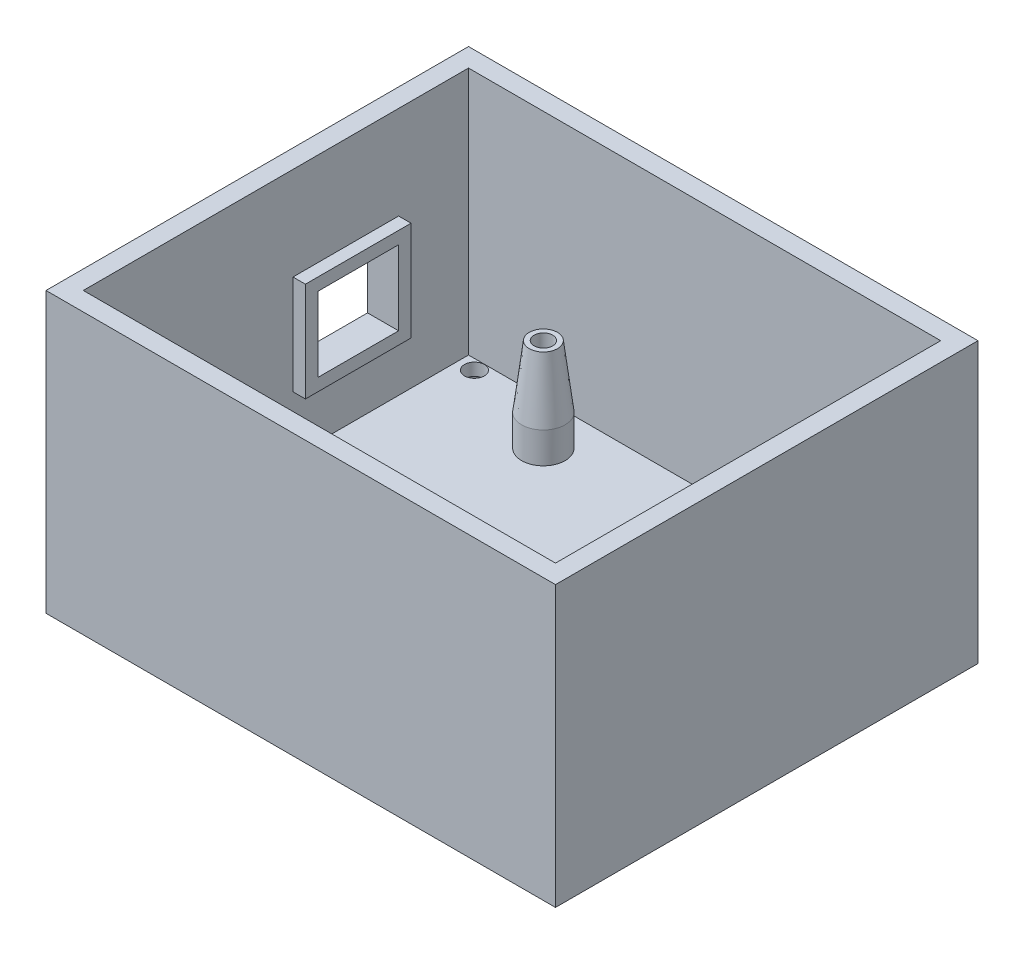
from build123d import *

# Parameters (mm, degrees)
SKETCH1_W           = 82
SKETCH1_H           = 68
BOSS_EXTRUDE1_DEPTH = 5
SKETCH2_W           = 82
SKETCH2_H           = 68
SKETCH2_W_2         = 76
SKETCH2_H_2         = 62
BOSS_EXTRUDE2_DEPTH = 40
SKETCH_1_R          = 3.5
SKETCH_1_R_2        = 1.5
BOSS_EXTRUDE3_DEPTH = 15
SKETCH4_W           = 13
SKETCH4_H           = 12
CUT_EXTRUDE1_DEPTH  = 3
SKETCH5_R           = 1.6
CUT_EXTRUDE2_DEPTH  = 46
SKETCH6_W           = 1.038961039
SKETCH6_H           = 16
SKETCH6_W_2         = 1.038961038
SKETCH6_W_3         = 0.935064935
SKETCH6_H_2         = 6
BOSS_EXTRUDE4_DEPTH = 1
SKETCH7_R           = 1.6
CUT_EXTRUDE3_DEPTH  = 46.0000001
CUT_EXTRUDE4_DEPTH  = 3
SKETCH10_W          = 17
SKETCH10_H          = 16
SKETCH10_W_2        = 13
SKETCH10_H_2        = 12
BOSS_EXTRUDE6_DEPTH = 2
CHAMFER1_SIZE       = 10
CHAMFER1_SIZE2      = 1.227845609
CUT_EXTRUDE5_DEPTH  = 3


with BuildPart() as part:
    # Sketch1 → Boss-Extrude1 (new body)
    with BuildSketch(Plane(origin=(0, 0, 0), x_dir=(1, 0, 0), z_dir=(0, 1, 0))):
        Rectangle(SKETCH1_W, SKETCH1_H)
    extrude(amount=BOSS_EXTRUDE1_DEPTH)

    # Sketch2 → Boss-Extrude2 (add)
    with BuildSketch(Plane(origin=(0, 5, 0), x_dir=(1, 0, 0), z_dir=(0, 1, 0))):
        Rectangle(SKETCH2_W, SKETCH2_H)
        Rectangle(SKETCH2_W_2, SKETCH2_H_2, mode=Mode.SUBTRACT)
    extrude(amount=BOSS_EXTRUDE2_DEPTH)

    # Эскиз1 → Boss-Extrude3 (add)
    with BuildSketch(Plane(origin=(0, 5, 0), x_dir=(1, 0, 0), z_dir=(0, 1, 0))):
        with Locations(Location((-20.3, -24.15, 0), (0, 0, 90))):  # turned: the seam where the file's is
            Circle(SKETCH_1_R)
        with Locations(Location((-20.3, -24.15, 0), (0, 0, 270))):  # turned: the seam where the file's is
            Circle(SKETCH_1_R_2, mode=Mode.SUBTRACT)
        with Locations(Location((-19, 24.05, 0), (0, 0, 90))):  # turned: the seam where the file's is
            Circle(SKETCH_1_R)
        with Locations(Location((-19, 24.05, 0), (0, 0, 270))):  # turned: the seam where the file's is
            Circle(SKETCH_1_R_2, mode=Mode.SUBTRACT)
        with Locations(Location((31.8, 8.85, 0), (0, 0, 90))):  # turned: the seam where the file's is
            Circle(SKETCH_1_R)
        with Locations(Location((31.8, 8.85, 0), (0, 0, 270))):  # turned: the seam where the file's is
            Circle(SKETCH_1_R_2, mode=Mode.SUBTRACT)
        with Locations(Location((31.8, -19.05, 0), (0, 0, 90))):  # turned: the seam where the file's is
            Circle(SKETCH_1_R)
        with Locations(Location((31.8, -19.05, 0), (0, 0, 270))):  # turned: the seam where the file's is
            Circle(SKETCH_1_R_2, mode=Mode.SUBTRACT)
    extrude(amount=BOSS_EXTRUDE3_DEPTH)

    # Sketch4 → Cut-Extrude1 (cut)
    with BuildSketch(Plane.ZY.offset(41)):
        with Locations((-11.25, 22)):
            Rectangle(SKETCH4_W, SKETCH4_H)
    extrude(amount=-CUT_EXTRUDE1_DEPTH, mode=Mode.SUBTRACT)

    # Sketch5 → Cut-Extrude2 (cut, through all)
    with BuildSketch(Plane.XZ):
        with Locations(Location((-20, 0, 0), (0, 0, 270))):  # turned: the seam where the file's is
            Circle(SKETCH5_R)
        with Locations(Location((20, 0, 0), (0, 0, 270))):  # turned: the seam where the file's is
            Circle(SKETCH5_R)
    extrude(amount=-CUT_EXTRUDE2_DEPTH, mode=Mode.SUBTRACT)

    # Sketch6 → Boss-Extrude4 (add)
    with BuildSketch(Plane(origin=(0, 0, -34), x_dir=(-1, 0, 0), z_dir=(0, 0, -1))):
        with BuildLine():
            Line((-31.064935065, 20.402597403), (-30.025974026, 20.61038961))
            add(Edge.make_bspline(
                [(-30.025974026, 20.61038961), (-30.016868414, 20.484792918), (-29.999188975, 20.240934613), (-29.963126926, 19.888060515), (-29.922684502, 19.558454016), (-29.868885391, 19.254851974), (-29.815998127, 18.973437018), (-29.750829493, 18.717933849), (-29.679471521, 18.485959946), (-29.602554708, 18.278361569), (-29.518303648, 18.094044446), (-29.424992346, 17.9348933), (-29.323309249, 17.800144607), (-29.217010337, 17.687767881), (-29.101116364, 17.602086662), (-28.980181431, 17.538341624), (-28.849524042, 17.501328913), (-28.759967332, 17.496148797), (-28.714285714, 17.493506494)],
                knots=[0, 0, 0, 0, 1.661687727, 3.226329817, 4.680708754, 6.04252312, 7.294539854, 8.458411098, 9.519995036, 10.49619686, 11.377985793, 12.191180799, 12.925279752, 13.601980054, 14.224680614, 14.818714541, 15.397442913, 16, 16, 16, 16], degree=3))
            add(Edge.make_bspline(
                [(-28.714285714, 17.493506494), (-28.626175383, 17.500509622), (-28.449894153, 17.514520693), (-28.207810204, 17.6461628), (-27.999947032, 17.851229771), (-27.833671953, 18.130415132), (-27.701639144, 18.463631904), (-27.600422532, 18.838132976), (-27.542705985, 19.251458609), (-27.53597212, 19.538778349), (-27.532467532, 19.688311688)],
                knots=[0, 0, 0, 0, 0.766738448, 1.534003965, 2.351769453, 3.301198784, 4.355496104, 5.484396366, 6.690773518, 8, 8, 8, 8], degree=3))
            add(Edge.make_bspline(
                [(-27.532467532, 19.688311688), (-27.533389047, 19.776023561), (-27.535167264, 19.945278246), (-27.557846971, 20.189547654), (-27.596587743, 20.413063993), (-27.663390633, 20.677065304), (-27.783838204, 20.969797211), (-27.97376884, 21.225964657), (-28.187671526, 21.415109589), (-28.416744466, 21.594638473), (-28.711370171, 21.820842523), (-28.9374622, 21.976282127), (-29.061688312, 22.061688312)],
                knots=[0, 0, 0, 0, 0.876287264, 1.6909424, 2.448383105, 3.140885154, 4.410446652, 5.584964704, 6.289190717, 7.258693585, 8.493791056, 10, 10, 10, 10], degree=3))
            add(Edge.make_bspline(
                [(-29.061688312, 22.061688312), (-29.176027715, 22.144958584), (-29.396314269, 22.305387279), (-29.687605647, 22.574624434), (-29.933601391, 22.852159883), (-30.132337823, 23.152195988), (-30.291814378, 23.482805462), (-30.434092879, 23.851134876), (-30.560507571, 24.264385407), (-30.664991897, 24.720419442), (-30.752188862, 25.207848635), (-30.813484827, 25.719495048), (-30.849036698, 26.248407051), (-30.854415503, 26.607089174), (-30.857142857, 26.788961039)],
                knots=[0, 0, 0, 0, 0.963949184, 1.857146694, 2.699365597, 3.487487385, 4.302789044, 5.197814381, 6.178376633, 7.247190379, 8.386632243, 9.553870898, 10.759675959, 12, 12, 12, 12], degree=3))
            add(Edge.make_bspline(
                [(-30.857142857, 26.788961039), (-30.854088378, 26.999000885), (-30.848128221, 27.408848298), (-30.799885602, 28.008787466), (-30.714577868, 28.575439797), (-30.604547612, 29.107114264), (-30.460010213, 29.58896524), (-30.294001435, 30.015155377), (-30.098806507, 30.377162712), (-29.878519584, 30.677513141), (-29.628480853, 30.915703506), (-29.346923858, 31.084038645), (-29.037809403, 31.191192244), (-28.821215613, 31.202195225), (-28.711038961, 31.207792208)],
                knots=[0, 0, 0, 0, 1.401640024, 2.734997902, 4.012817877, 5.223990224, 6.355074786, 7.366334982, 8.271317923, 9.091800892, 9.842980832, 10.558924655, 11.266955634, 12, 12, 12, 12], degree=3))
            add(Edge.make_bspline(
                [(-28.711038961, 31.207792208), (-28.627370875, 31.204138543), (-28.462252224, 31.196928051), (-28.222436212, 31.136840846), (-27.99884274, 31.03686606), (-27.786960968, 30.902088863), (-27.591899336, 30.724420824), (-27.414006672, 30.506989796), (-27.24644712, 30.254107306), (-27.096667117, 29.962567439), (-26.959967183, 29.63583311), (-26.840317666, 29.27559408), (-26.741198491, 28.881243436), (-26.657070805, 28.455305488), (-26.589518587, 27.995855065), (-26.537514645, 27.503096433), (-26.505933925, 26.976566886), (-26.497728837, 26.614758323), (-26.493506494, 26.428571429)],
                knots=[0, 0, 0, 0, 0.695412281, 1.372393508, 2.041605889, 2.725971717, 3.452793057, 4.226354358, 5.057948934, 5.972157744, 6.948753067, 8.002263538, 9.126939128, 10.329474995, 11.613047353, 12.989221996, 14.450651905, 16, 16, 16, 16], degree=3))
            Line((-26.493506494, 26.428571429), (-27.532467532, 26.220779221))
            add(Edge.make_bspline(
                [(-27.532467532, 26.220779221), (-27.54093835, 26.322517805), (-27.557262626, 26.518580213), (-27.583864063, 26.80176955), (-27.624974622, 27.059954024), (-27.664323563, 27.296009856), (-27.717617625, 27.505485276), (-27.771595461, 27.692649748), (-27.833098451, 27.855684632), (-27.919708269, 28.036784602), (-28.051627643, 28.219924842), (-28.241242291, 28.390288951), (-28.471179714, 28.487943746), (-28.634428531, 28.500235983), (-28.717532468, 28.506493506)],
                knots=[0, 0, 0, 0, 1.296485935, 2.498483323, 3.610200847, 4.615676197, 5.535617839, 6.35305, 7.08812514, 7.745768663, 8.89761878, 9.930610951, 10.946550552, 12, 12, 12, 12], degree=3))
            add(Edge.make_bspline(
                [(-28.717532468, 28.506493506), (-28.801659454, 28.501207248), (-28.963775423, 28.491020421), (-29.191742714, 28.402069528), (-29.384731707, 28.252979321), (-29.54317232, 28.052133814), (-29.663284564, 27.809548914), (-29.755709635, 27.539175905), (-29.80631869, 27.238860673), (-29.814122301, 27.030479772), (-29.818181818, 26.922077922)],
                knots=[0, 0, 0, 0, 0.934315741, 1.800462716, 2.677856118, 3.620837444, 4.623395376, 5.679091747, 6.792640076, 8, 8, 8, 8], degree=3))
            add(Edge.make_bspline(
                [(-29.818181818, 26.922077922), (-29.815762732, 26.815903924), (-29.811079789, 26.610369008), (-29.773264745, 26.315046987), (-29.705698425, 26.045889087), (-29.639247267, 25.88141168), (-29.607142857, 25.801948052)],
                knots=[0, 0, 0, 0, 1.109407768, 2.147625928, 3.105066361, 4, 4, 4, 4], degree=3))
            add(Edge.make_bspline(
                [(-29.607142857, 25.801948052), (-29.562259177, 25.722088538), (-29.464233792, 25.547676375), (-29.239045117, 25.306855717), (-28.952878832, 25.048346495), (-28.726049547, 24.888194206), (-28.603896104, 24.801948052)],
                knots=[0, 0, 0, 0, 0.766139538, 1.673238994, 2.746978949, 4, 4, 4, 4], degree=3))
            add(Edge.make_bspline(
                [(-28.603896104, 24.801948052), (-28.471194165, 24.705683014), (-28.215551055, 24.520233622), (-27.874570387, 24.216793123), (-27.58267654, 23.912803586), (-27.340341615, 23.595565767), (-27.142129231, 23.250531829), (-26.970744907, 22.869882925), (-26.824120553, 22.443902606), (-26.70659348, 21.970875705), (-26.608007051, 21.450883299), (-26.542546829, 20.877976083), (-26.499314709, 20.253918658), (-26.495488945, 19.819345066), (-26.493506494, 19.594155844)],
                knots=[0, 0, 0, 0, 1.000609751, 1.927620585, 2.783153281, 3.570961003, 4.358768726, 5.20766402, 6.116857726, 7.105875995, 8.181749998, 9.346629881, 10.625065205, 12, 12, 12, 12], degree=3))
            add(Edge.make_bspline(
                [(-26.493506494, 19.594155844), (-26.495564417, 19.428537494), (-26.499615535, 19.102510113), (-26.525887953, 18.623816115), (-26.567588729, 18.165629126), (-26.62571662, 17.727772874), (-26.702054851, 17.310104134), (-26.801812767, 16.913523645), (-26.909903396, 16.534989898), (-27.038947347, 16.181401769), (-27.180583092, 15.85684851), (-27.348137438, 15.573229072), (-27.533899041, 15.331920141), (-27.743428192, 15.136480367), (-27.968186401, 14.979965469), (-28.216702701, 14.872549814), (-28.483454126, 14.805039048), (-28.66841944, 14.796548679), (-28.762987013, 14.792207792)],
                knots=[0, 0, 0, 0, 1.361063224, 2.679315891, 3.938706896, 5.141224642, 6.308254959, 7.425663367, 8.500786559, 9.541817607, 10.517134937, 11.406414363, 12.242651655, 13.010333969, 13.752873856, 14.481649864, 15.223710195, 16, 16, 16, 16], degree=3))
            add(Edge.make_bspline(
                [(-28.762987013, 14.792207792), (-28.846736443, 14.796725665), (-29.012472556, 14.805666319), (-29.254183422, 14.873089435), (-29.480235594, 14.985265569), (-29.691676934, 15.141799861), (-29.886361989, 15.342153191), (-30.065948619, 15.586536423), (-30.229802019, 15.874042819), (-30.383456343, 16.203597737), (-30.516868914, 16.57851733), (-30.641500514, 16.995286126), (-30.74571929, 17.456860512), (-30.841062972, 17.961219299), (-30.916672782, 18.509769125), (-30.981319083, 19.101995016), (-31.034122323, 19.737430352), (-31.054453179, 20.176320709), (-31.064935065, 20.402597403)],
                knots=[0, 0, 0, 0, 0.612608553, 1.212323001, 1.821797986, 2.45093849, 3.128876999, 3.859410453, 4.665290398, 5.54794541, 6.517989402, 7.575918137, 8.731006535, 9.980425418, 11.332895035, 12.783613092, 14.341742115, 16, 16, 16, 16], degree=3))
        make_face()
        with Locations((-25.350649351, 23)):
            Rectangle(SKETCH6_W, SKETCH6_H)
        Polygon((-23.792207792, 15), (-23.792207792, 31), (-22.00974026, 31), (-20.987012987, 19.876623377), (-19.951298701, 31), (-18.181818182, 31), (-18.181818182, 15), (-19.220779221, 15), (-19.220779221, 27.801948052), (-20.418831169, 15), (-21.571428571, 15), (-22.753246753, 27.801948052), (-22.753246753, 15), align=None)
        with BuildLine():
            Line((-13.402597403, 20.818181818), (-12.363636364, 19.779220779))
            add(Edge.make_bspline(
                [(-12.363636364, 19.779220779), (-12.386467637, 19.570232215), (-12.430658399, 19.165727216), (-12.510577783, 18.581779306), (-12.604711967, 18.042645862), (-12.70908755, 17.54679032), (-12.819986466, 17.09293018), (-12.946623733, 16.683414264), (-13.082677768, 16.317826308), (-13.227642833, 15.99472085), (-13.384947545, 15.712907118), (-13.548794546, 15.467439517), (-13.725748923, 15.261994813), (-13.907008426, 15.089221039), (-14.101659799, 14.957597566), (-14.304672919, 14.8609992), (-14.51861994, 14.804294505), (-14.66418578, 14.796238331), (-14.737012987, 14.792207792)],
                knots=[0, 0, 0, 0, 1.701001102, 3.292349753, 4.767988866, 6.128194562, 7.391872584, 8.546870257, 9.594320478, 10.546596534, 11.409038328, 12.203253684, 12.929854531, 13.59904593, 14.2232384, 14.822613538, 15.410948564, 16, 16, 16, 16], degree=3))
            add(Edge.make_bspline(
                [(-14.737012987, 14.792207792), (-14.828819832, 14.797209435), (-15.013100005, 14.80724903), (-15.277918471, 14.910038589), (-15.529504281, 15.065523915), (-15.764356264, 15.285927941), (-15.985852005, 15.564920121), (-16.187068131, 15.907492601), (-16.384778533, 16.305580313), (-16.494117466, 16.598381125), (-16.551948052, 16.753246753)],
                knots=[0, 0, 0, 0, 0.77182, 1.549243122, 2.365629293, 3.257973415, 4.252460229, 5.363344568, 6.605443417, 8, 8, 8, 8], degree=3))
            add(Edge.make_bspline(
                [(-16.551948052, 16.753246753), (-16.617232627, 16.949469012), (-16.7519809, 17.354474487), (-16.910850116, 17.996277056), (-17.047660411, 18.686385026), (-17.15554071, 19.425739809), (-17.242888962, 20.214083197), (-17.308769919, 21.052062568), (-17.342412985, 21.94019453), (-17.347859314, 22.548677108), (-17.350649351, 22.86038961)],
                knots=[0, 0, 0, 0, 0.801995648, 1.655330184, 2.562717319, 3.530566656, 4.55291452, 5.639384362, 6.790707516, 8, 8, 8, 8], degree=3))
            add(Edge.make_bspline(
                [(-17.350649351, 22.86038961), (-17.34839296, 23.1894404), (-17.344004682, 23.829385626), (-17.303323886, 24.761508747), (-17.243891592, 25.638789614), (-17.156867978, 26.460917916), (-17.043953966, 27.229083005), (-16.905729596, 27.942309129), (-16.74238938, 28.600828733), (-16.60731635, 29.014760376), (-16.542207792, 29.214285714)],
                knots=[0, 0, 0, 0, 1.227556515, 2.387378961, 3.480244526, 4.5075745, 5.470885637, 6.375980359, 7.217182174, 8, 8, 8, 8], degree=3))
            add(Edge.make_bspline(
                [(-16.542207792, 29.214285714), (-16.484198637, 29.371172692), (-16.373968175, 29.669293288), (-16.177160075, 30.07727724), (-15.961189625, 30.421302093), (-15.736412423, 30.708983293), (-15.489450088, 30.93169884), (-15.227082648, 31.091931928), (-14.945822319, 31.188016559), (-14.752870538, 31.201175297), (-14.655844156, 31.207792208)],
                knots=[0, 0, 0, 0, 1.371482154, 2.606125015, 3.707000103, 4.698200735, 5.590904225, 6.419046966, 7.20501302, 8, 8, 8, 8], degree=3))
            add(Edge.make_bspline(
                [(-14.655844156, 31.207792208), (-14.576341948, 31.203542163), (-14.418649246, 31.195112196), (-14.187449943, 31.122496642), (-13.969838588, 31.002508214), (-13.757979509, 30.841962292), (-13.564435857, 30.628090938), (-13.375248851, 30.374967102), (-13.200882807, 30.072422439), (-13.096856904, 29.85253104), (-13.042207792, 29.737012987)],
                knots=[0, 0, 0, 0, 0.824223876, 1.634848824, 2.489692048, 3.395614922, 4.381593142, 5.474051104, 6.673014496, 8, 8, 8, 8], degree=3))
            add(Edge.make_bspline(
                [(-13.042207792, 29.737012987), (-13.003070499, 29.645511816), (-12.921253262, 29.454226919), (-12.818910826, 29.144442333), (-12.72675483, 28.802128282), (-12.634747612, 28.430388199), (-12.554030709, 28.026265112), (-12.483882462, 27.590624936), (-12.418818311, 27.124062538), (-12.382382126, 26.802038976), (-12.363636364, 26.636363636)],
                knots=[0, 0, 0, 0, 0.749492121, 1.566827203, 2.454986547, 3.420019814, 4.451384554, 5.558566959, 6.743926548, 8, 8, 8, 8], degree=3))
            Line((-12.363636364, 26.636363636), (-13.402597403, 25.805194805))
            add(Edge.make_bspline(
                [(-13.402597403, 25.805194805), (-13.424621563, 26.010129679), (-13.466201564, 26.397031696), (-13.568398697, 26.938465772), (-13.701924724, 27.405132073), (-13.865607251, 27.793813043), (-14.050439741, 28.104691985), (-14.256767033, 28.328848686), (-14.482571267, 28.482683413), (-14.649473485, 28.498710782), (-14.730519481, 28.506493506)],
                knots=[0, 0, 0, 0, 1.533771726, 2.895648567, 4.096281718, 5.139246492, 6.029034683, 6.769902215, 7.402677203, 8, 8, 8, 8], degree=3))
            add(Edge.make_bspline(
                [(-14.730519481, 28.506493506), (-14.788350675, 28.5027585), (-14.903799231, 28.495302296), (-15.071668001, 28.43348531), (-15.224995844, 28.328027396), (-15.374057325, 28.188951901), (-15.512346469, 28.008261593), (-15.642137604, 27.787297349), (-15.76373512, 27.52825474), (-15.877987996, 27.228948016), (-15.983385001, 26.885860215), (-16.067020918, 26.490833899), (-16.146744002, 26.046253634), (-16.205367915, 25.548477776), (-16.255123537, 25.000745007), (-16.284271687, 24.400647807), (-16.309578752, 23.750211348), (-16.310968591, 23.298731595), (-16.311688312, 23.064935065)],
                knots=[0, 0, 0, 0, 0.459735518, 0.917771154, 1.403055803, 1.933609353, 2.535350466, 3.20792421, 3.971295311, 4.811656191, 5.757767915, 6.826340077, 8.025152651, 9.35401964, 10.816390696, 12.404663811, 14.138173149, 16, 16, 16, 16], degree=3))
            add(Edge.make_bspline(
                [(-16.311688312, 23.064935065), (-16.310585552, 22.822493607), (-16.308463338, 22.355925104), (-16.28836922, 21.682633214), (-16.258457782, 21.063126495), (-16.208343461, 20.498196734), (-16.151540243, 19.987927643), (-16.08277284, 19.532080685), (-15.993584422, 19.1318198), (-15.89921098, 18.781205706), (-15.785778039, 18.480224688), (-15.671949113, 18.218645979), (-15.543985441, 17.997730153), (-15.409294474, 17.816623745), (-15.269369861, 17.670303561), (-15.115255767, 17.571521918), (-14.954513686, 17.503991423), (-14.841544777, 17.49697439), (-14.785714286, 17.493506494)],
                knots=[0, 0, 0, 0, 1.899615963, 3.655731919, 5.277647585, 6.758655983, 8.098751765, 9.30053347, 10.368418967, 11.310777956, 12.142518779, 12.886450387, 13.543862524, 14.137468852, 14.653153183, 15.118863812, 15.564532702, 16, 16, 16, 16], degree=3))
            add(Edge.make_bspline(
                [(-14.785714286, 17.493506494), (-14.744334797, 17.496194809), (-14.66218973, 17.501531555), (-14.541495182, 17.539251492), (-14.426492025, 17.602907895), (-14.315275522, 17.691463484), (-14.212428767, 17.807782052), (-14.110546288, 17.945292554), (-14.014957535, 18.108402138), (-13.918859647, 18.294737368), (-13.832400876, 18.510292232), (-13.751605645, 18.754364169), (-13.677606471, 19.027641179), (-13.60953928, 19.329900695), (-13.54993367, 19.660711622), (-13.489010835, 20.019435314), (-13.442215782, 20.408585634), (-13.416106366, 20.678518861), (-13.402597403, 20.818181818)],
                knots=[0, 0, 0, 0, 0.518282682, 1.028876079, 1.569060259, 2.157966214, 2.80122392, 3.509289564, 4.30020441, 5.167669335, 6.134912674, 7.207247173, 8.388568547, 9.681787947, 11.089122292, 12.601015063, 14.241371423, 16, 16, 16, 16], degree=3))
        make_face()
        Polygon((-11.532467532, 15), (-11.532467532, 31), (-10.493506494, 31), (-10.493506494, 24.766233766), (-8.207792208, 24.766233766), (-8.207792208, 31), (-7.168831169, 31), (-7.168831169, 15), (-8.207792208, 15), (-8.207792208, 22.064935065), (-10.493506494, 22.064935065), (-10.493506494, 15), align=None)
        Polygon((-0.935064935, 15), (-2.022727273, 15), (-2.519480519, 18.532467532), (-4.954545455, 18.532467532), (-5.451298701, 15), (-6.545454545, 15), (-4.305194805, 31), (-3.178571429, 31), align=None)
        Polygon((-2.899350649, 21.233766234), (-3.74025974, 27.230519481), (-4.577922078, 21.233766234), align=None, mode=Mode.SUBTRACT)
        with Locations((0, 23)):
            Rectangle(SKETCH6_W_2, SKETCH6_H)
        with BuildLine():
            Line((1.766233766, 15), (1.766233766, 31))
            Line((1.766233766, 31), (4.142857143, 31))
            add(Edge.make_bspline(
                [(4.142857143, 31), (4.283966528, 30.995944534), (4.548346531, 30.988346285), (4.914153133, 30.909459854), (5.216842003, 30.773159063), (5.460612769, 30.57266883), (5.646778525, 30.298522422), (5.81419194, 29.960374456), (5.96540879, 29.544271149), (6.09430419, 29.053793321), (6.203330966, 28.498689674), (6.284889242, 27.886264364), (6.327950162, 27.22032361), (6.334347064, 26.758714934), (6.337662338, 26.519480519)],
                knots=[0, 0, 0, 0, 0.902700593, 1.691283569, 2.379628515, 3.009678129, 3.684847453, 4.484529897, 5.423075934, 6.514199806, 7.729354384, 9.043803498, 10.467914539, 12, 12, 12, 12], degree=3))
            add(Edge.make_bspline(
                [(6.337662338, 26.519480519), (6.336053901, 26.366880892), (6.332915968, 26.069171179), (6.319035512, 25.633639182), (6.284349755, 25.221387881), (6.24440011, 24.831155125), (6.187628685, 24.464408265), (6.125641381, 24.118829381), (6.042752632, 23.797786834), (5.952879027, 23.499534059), (5.853848402, 23.224938931), (5.738485341, 22.97931225), (5.621410371, 22.755560119), (5.485214243, 22.563178746), (5.34458715, 22.392929076), (5.189531474, 22.250943355), (5.024287699, 22.13623205), (4.905590309, 22.07967392), (4.847402597, 22.051948052)],
                knots=[0, 0, 0, 0, 1.485096717, 2.897305346, 4.238950977, 5.510130277, 6.713586432, 7.849626886, 8.924979266, 9.937760979, 10.880730992, 11.761925901, 12.577219587, 13.333879874, 14.051262626, 14.72214744, 15.373572443, 16, 16, 16, 16], degree=3))
            add(Edge.make_bspline(
                [(4.847402597, 22.051948052), (4.961166425, 21.8445695), (5.193038819, 21.421892428), (5.379272322, 20.901763772), (5.498471312, 20.524962486), (5.560924724, 20.289819378), (5.637672897, 20.021500566), (5.715108479, 19.715005305), (5.795009948, 19.371361165), (5.882847259, 18.991528157), (5.977347473, 18.574933975), (6.041289988, 18.284668695), (6.074675325, 18.133116883)],
                knots=[0, 0, 0, 0, 1.718249585, 3.502120622, 4.005105704, 4.593395491, 5.271445958, 6.035210625, 6.89260229, 7.837905462, 8.871138346, 10, 10, 10, 10], degree=3))
            Line((6.074675325, 18.133116883), (6.753246753, 15))
            Line((6.753246753, 15), (5.353896104, 15))
            Line((5.353896104, 15), (4.594155844, 18.503246753))
            add(Edge.make_bspline(
                [(4.594155844, 18.503246753), (4.561776658, 18.65369657), (4.5000073, 18.94070775), (4.410909148, 19.348074571), (4.323491936, 19.709659684), (4.253662516, 20.027442932), (4.176991012, 20.296906528), (4.12400295, 20.524430066), (4.066057353, 20.703821032), (4.009468257, 20.879986958), (3.937401639, 21.053805979), (3.853135013, 21.229791685), (3.760642893, 21.368937367), (3.665398036, 21.479310526), (3.548812519, 21.560218116), (3.407514493, 21.613193717), (3.238480304, 21.645721227), (3.117052908, 21.648083882), (3.051948052, 21.649350649)],
                knots=[0, 0, 0, 0, 1.948703902, 3.717517379, 5.279823375, 6.659297508, 7.835999957, 8.8264809, 9.615378786, 10.222076803, 11.168738396, 11.996096083, 12.687838253, 13.279650514, 13.830881723, 14.464530193, 15.176738168, 16, 16, 16, 16], degree=3))
            Line((3.051948052, 21.649350649), (2.805194805, 21.649350649))
            Line((2.805194805, 21.649350649), (2.805194805, 15))
            Line((2.805194805, 15), (1.766233766, 15))
        make_face()
        with BuildLine():
            Line((2.805194805, 24.350649351), (3.720779221, 24.350649351))
            add(Edge.make_bspline(
                [(3.720779221, 24.350649351), (3.847484, 24.351920306), (4.076417704, 24.354216705), (4.381567174, 24.383171335), (4.613633363, 24.421901604), (4.785301661, 24.490570414), (4.901607219, 24.604352431), (5.002708567, 24.740096881), (5.085109234, 24.919409277), (5.163908231, 25.132244563), (5.223176452, 25.387530124), (5.268363792, 25.679342907), (5.292986296, 26.010412394), (5.296722716, 26.243469896), (5.298701299, 26.366883117)],
                knots=[0, 0, 0, 0, 1.482886096, 2.679319681, 3.583789171, 4.236021242, 4.801083894, 5.462481267, 6.210445108, 7.100241717, 8.117404996, 9.271425656, 10.555111314, 12, 12, 12, 12], degree=3))
            add(Edge.make_bspline(
                [(5.298701299, 26.366883117), (5.296664511, 26.484886238), (5.292791087, 26.709296527), (5.26864621, 27.027418359), (5.223192884, 27.308559184), (5.162882755, 27.553497905), (5.086068589, 27.763352369), (4.993433453, 27.936134796), (4.896928441, 28.083086513), (4.810384241, 28.150130787), (4.769480519, 28.181818182)],
                knots=[0, 0, 0, 0, 1.452238813, 2.761768756, 3.922215494, 4.952638315, 5.862967632, 6.661285263, 7.367278063, 8, 8, 8, 8], degree=3))
            add(Edge.make_bspline(
                [(4.769480519, 28.181818182), (4.727831011, 28.200989181), (4.62202097, 28.249692858), (4.407099115, 28.273258593), (4.116600539, 28.298032825), (3.894126217, 28.298461259), (3.769480519, 28.298701299)],
                knots=[0, 0, 0, 0, 0.539780944, 1.371306565, 2.527221815, 4, 4, 4, 4], degree=3))
            Line((3.769480519, 28.298701299), (2.805194805, 28.298701299))
            Line((2.805194805, 28.298701299), (2.805194805, 24.350649351))
        make_face(mode=Mode.SUBTRACT)
        Polygon((9.246753247, 15), (9.246753247, 31), (11.029220779, 31), (12.051948052, 19.876623377), (13.087662338, 31), (14.857142857, 31), (14.857142857, 15), (13.818181818, 15), (13.818181818, 27.801948052), (12.62012987, 15), (11.467532468, 15), (10.285714286, 27.801948052), (10.285714286, 15), align=None)
        Polygon((15.896103896, 15), (15.896103896, 31), (16.935064935, 31), (16.935064935, 23.672077922), (19.448051948, 31), (20.779220779, 31), (18.623376623, 24.711038961), (20.987012987, 15), (19.561688312, 15), (17.886363636, 22.561688312), (16.935064935, 19.779220779), (16.935064935, 15), align=None)
        with Locations((23.896103897, 23)):
            Rectangle(SKETCH6_W, SKETCH6_H)
        with Locations((25.974025975, 23)):
            Rectangle(SKETCH6_W, SKETCH6_H)
        with Locations((28.051948052, 23)):
            Rectangle(SKETCH6_W, SKETCH6_H)
        with Locations((-19.363636363, 10)):
            Rectangle(SKETCH6_W_3, SKETCH6_H_2)
        with BuildLine():
            Line((-14.922077922, 8.012987013), (-14.922077922, 7))
            Line((-14.922077922, 7), (-18.272727273, 7))
            add(Edge.make_bspline(
                [(-18.272727273, 7), (-18.260938164, 7.099768731), (-18.237391976, 7.299035127), (-18.166092998, 7.591498092), (-18.069983052, 7.877208415), (-17.964742296, 8.109854886), (-17.860304016, 8.297699232), (-17.766876896, 8.450964935), (-17.655615325, 8.614055351), (-17.526652255, 8.786749501), (-17.383655542, 8.971606455), (-17.22346258, 9.166687387), (-17.046907652, 9.372164091), (-16.92232078, 9.511577644), (-16.857954545, 9.583603896)],
                knots=[0, 0, 0, 0, 1.20268352, 2.402099407, 3.598367202, 4.810420478, 5.454599206, 6.172593709, 6.960183653, 7.818888272, 8.754527026, 9.759992126, 10.842728215, 12, 12, 12, 12], degree=3))
            add(Edge.make_bspline(
                [(-16.857954545, 9.583603896), (-16.807487232, 9.63989061), (-16.710938755, 9.747572119), (-16.575134938, 9.903505055), (-16.45297981, 10.04372674), (-16.348366298, 10.171131917), (-16.257608161, 10.283056627), (-16.182391956, 10.38120706), (-16.121815605, 10.464732363), (-16.089437549, 10.517283377), (-16.075081169, 10.540584416)],
                knots=[0, 0, 0, 0, 1.465870871, 2.804341841, 4.009590698, 5.071600616, 6.000740577, 6.80347298, 7.469461756, 8, 8, 8, 8], degree=3))
            add(Edge.make_bspline(
                [(-16.075081169, 10.540584416), (-16.041762173, 10.600271049), (-15.976722757, 10.716780678), (-15.908994485, 10.901410832), (-15.864724517, 11.086373848), (-15.859651407, 11.210796795), (-15.857142857, 11.272321429)],
                knots=[0, 0, 0, 0, 1.060288104, 2.069705834, 3.04550853, 4, 4, 4, 4], degree=3))
            add(Edge.make_bspline(
                [(-15.857142857, 11.272321429), (-15.859297528, 11.333793939), (-15.863376458, 11.45016534), (-15.898285008, 11.61275597), (-15.956643594, 11.752581674), (-16.040995143, 11.86610846), (-16.143685576, 11.955222631), (-16.262131496, 12.020251405), (-16.396183345, 12.05877364), (-16.49041196, 12.062839979), (-16.538961039, 12.064935065)],
                knots=[0, 0, 0, 0, 1.245810787, 2.358399634, 3.353971925, 4.295778042, 5.200327805, 6.09189762, 7.016895116, 8, 8, 8, 8], degree=3))
            add(Edge.make_bspline(
                [(-16.538961039, 12.064935065), (-16.591607395, 12.062634516), (-16.692513362, 12.05822511), (-16.834433701, 12.017173124), (-16.957613257, 11.94950148), (-17.058555177, 11.851285976), (-17.141400781, 11.728582222), (-17.201213618, 11.577751689), (-17.242222576, 11.40165973), (-17.253668227, 11.274991154), (-17.25974026, 11.207792208)],
                knots=[0, 0, 0, 0, 0.999920937, 1.916523715, 2.784458762, 3.647604167, 4.570853193, 5.582015381, 6.717234977, 8, 8, 8, 8], degree=3))
            Line((-17.25974026, 11.207792208), (-18.194805195, 11.363636364))
            add(Edge.make_bspline(
                [(-18.194805195, 11.363636364), (-18.186975307, 11.431989588), (-18.171786253, 11.564586753), (-18.131566415, 11.755044153), (-18.083934528, 11.932075726), (-18.024293575, 12.094765293), (-17.953566745, 12.24332506), (-17.871514405, 12.377591271), (-17.780502336, 12.499823196), (-17.675937374, 12.60589096), (-17.561992044, 12.698686333), (-17.439435389, 12.779907012), (-17.307365112, 12.847822818), (-17.166933165, 12.904457025), (-17.016868556, 12.946386355), (-16.858697902, 12.978485181), (-16.691168515, 12.996589816), (-16.576746208, 12.998846546), (-16.518262987, 13)],
                knots=[0, 0, 0, 0, 1.257113927, 2.438652199, 3.554660598, 4.606291011, 5.601856267, 6.557471959, 7.478981492, 8.381416587, 9.2725261, 10.161501808, 11.064119884, 11.98308707, 12.924775989, 13.908409216, 14.930951759, 16, 16, 16, 16], degree=3))
            add(Edge.make_bspline(
                [(-16.518262987, 13), (-16.454036707, 12.998965675), (-16.329548514, 12.99696087), (-16.149212909, 12.970944461), (-15.980366885, 12.933876556), (-15.824671792, 12.87621848), (-15.679405563, 12.806861439), (-15.548776685, 12.717074003), (-15.427426997, 12.615310647), (-15.323385859, 12.49449837), (-15.228677703, 12.366799226), (-15.147359964, 12.232211513), (-15.076951936, 12.094307982), (-15.020846589, 11.950622532), (-14.97716751, 11.802271065), (-14.945689603, 11.649569567), (-14.925071104, 11.492446568), (-14.923085995, 11.386023849), (-14.922077922, 11.331980519)],
                knots=[0, 0, 0, 0, 1.185802577, 2.298411505, 3.360827086, 4.373838454, 5.359924385, 6.327149754, 7.295159843, 8.277960573, 9.264958702, 10.230903902, 11.180079425, 12.122922977, 13.076886226, 14.034409875, 15.001838751, 16, 16, 16, 16], degree=3))
            add(Edge.make_bspline(
                [(-14.922077922, 11.331980519), (-14.92310101, 11.270639109), (-14.92513215, 11.148857801), (-14.945991984, 10.967510193), (-14.976801079, 10.78868977), (-15.022503444, 10.612156036), (-15.081601473, 10.437010973), (-15.153565238, 10.261738254), (-15.238835727, 10.085762615), (-15.322803328, 9.939956348), (-15.398039868, 9.818822781), (-15.465035692, 9.721999781), (-15.541387448, 9.619514588), (-15.624954506, 9.509642788), (-15.719013558, 9.394499298), (-15.821270871, 9.272713868), (-15.932083989, 9.144858771), (-16.009613767, 9.058329393), (-16.049512987, 9.013798701)],
                knots=[0, 0, 0, 0, 1.112568374, 2.208785751, 3.308090549, 4.402946702, 5.513734595, 6.659701235, 7.83876403, 9.059051271, 9.71083511, 10.425746939, 11.194567613, 12.029688168, 12.930202216, 13.891926091, 14.915120021, 16, 16, 16, 16], degree=3))
            add(Edge.make_bspline(
                [(-16.049512987, 9.013798701), (-16.086458506, 8.972821566), (-16.156895754, 8.894697973), (-16.257363188, 8.782825795), (-16.345317196, 8.680197479), (-16.425032717, 8.590548012), (-16.493026185, 8.511245621), (-16.551031009, 8.443275736), (-16.596465291, 8.384637186), (-16.665282099, 8.298965995), (-16.747928328, 8.178375017), (-16.806591667, 8.066718136), (-16.834821429, 8.012987013)],
                knots=[0, 0, 0, 0, 1.297038255, 2.472825099, 3.534584971, 4.474279189, 5.292832013, 5.990344774, 6.574432518, 7.036342243, 8.573839243, 10, 10, 10, 10], degree=3))
            Line((-16.834821429, 8.012987013), (-14.922077922, 8.012987013))
        make_face()
        with BuildLine():
            Line((-10.948051948, 9.181818182), (-10.012987013, 8.792207792))
            add(Edge.make_bspline(
                [(-10.012987013, 8.792207792), (-10.03229877, 8.713606969), (-10.069928683, 8.560449385), (-10.141119292, 8.341544151), (-10.219456424, 8.138433434), (-10.309078501, 7.952254122), (-10.406912844, 7.781372797), (-10.515586894, 7.627470997), (-10.633056049, 7.489760734), (-10.759988445, 7.368563779), (-10.896178226, 7.264283485), (-11.037801533, 7.171359157), (-11.188515497, 7.095181001), (-11.346209717, 7.030860269), (-11.512123956, 6.983048496), (-11.684997637, 6.947068156), (-11.865572774, 6.926478529), (-11.988585955, 6.923561294), (-12.051136364, 6.922077922)],
                knots=[0, 0, 0, 0, 1.282586353, 2.499182829, 3.646034602, 4.730797578, 5.771318175, 6.763713287, 7.712684321, 8.6363956, 9.539720391, 10.428356747, 11.317388874, 12.212151588, 13.124116906, 14.050177375, 15.008543639, 16, 16, 16, 16], degree=3))
            add(Edge.make_bspline(
                [(-12.051136364, 6.922077922), (-12.129618084, 6.923842384), (-12.28336192, 6.927298924), (-12.507703721, 6.96449043), (-12.721184271, 7.020996446), (-12.923418758, 7.102139437), (-13.114646987, 7.205857459), (-13.292848803, 7.334327462), (-13.462182386, 7.482766727), (-13.560638201, 7.598505608), (-13.610795455, 7.657467532)],
                knots=[0, 0, 0, 0, 1.053414494, 2.063614103, 3.046293227, 4.01520277, 4.983805463, 5.961130836, 6.961320097, 8, 8, 8, 8], degree=3))
            add(Edge.make_bspline(
                [(-13.610795455, 7.657467532), (-13.665928355, 7.730263429), (-13.776998678, 7.876917492), (-13.916441302, 8.118749782), (-14.035039931, 8.378557934), (-14.132107058, 8.65657743), (-14.207765769, 8.953116281), (-14.26066103, 9.268315862), (-14.292426248, 9.602023712), (-14.296577903, 9.830691979), (-14.298701299, 9.947646104)],
                knots=[0, 0, 0, 0, 0.898140554, 1.809387162, 2.740718204, 3.705966939, 4.703925369, 5.74945803, 6.848943185, 8, 8, 8, 8], degree=3))
            add(Edge.make_bspline(
                [(-14.298701299, 9.947646104), (-14.296761423, 10.071107717), (-14.292982871, 10.311590223), (-14.258962732, 10.66170989), (-14.207100489, 10.991789408), (-14.129776037, 11.300601924), (-14.032910128, 11.589920664), (-13.913232576, 11.857941474), (-13.774274929, 12.107467443), (-13.660901372, 12.25649277), (-13.604707792, 12.330357143)],
                knots=[0, 0, 0, 0, 1.171098873, 2.281104103, 3.334483992, 4.338438261, 5.297974877, 6.225356982, 7.120398547, 8, 8, 8, 8], degree=3))
            add(Edge.make_bspline(
                [(-13.604707792, 12.330357143), (-13.553686798, 12.390064841), (-13.453135362, 12.507735906), (-13.281269039, 12.660111669), (-13.096630647, 12.789636495), (-12.899286998, 12.895684424), (-12.688355052, 12.978165041), (-12.464867162, 13.036364651), (-12.227928523, 13.070704753), (-12.065860651, 13.075479531), (-11.982954545, 13.077922078)],
                knots=[0, 0, 0, 0, 1.017460211, 2.005195831, 2.96880208, 3.936538458, 4.903086366, 5.898753713, 6.925103759, 8, 8, 8, 8], degree=3))
            add(Edge.make_bspline(
                [(-11.982954545, 13.077922078), (-11.915107106, 13.07629806), (-11.781756148, 13.073106129), (-11.586221148, 13.047588389), (-11.399925987, 13.002719011), (-11.221052152, 12.943864389), (-11.05116899, 12.865117511), (-10.889785277, 12.769562771), (-10.736266367, 12.65751432), (-10.643216127, 12.570407106), (-10.596185065, 12.52637987)],
                knots=[0, 0, 0, 0, 1.062174293, 2.087653736, 3.080296642, 4.058948008, 5.03139012, 6.005719887, 6.992016441, 8, 8, 8, 8], degree=3))
            add(Edge.make_bspline(
                [(-10.596185065, 12.52637987), (-10.563484824, 12.492447286), (-10.496850928, 12.423302224), (-10.407128238, 12.306831684), (-10.324060595, 12.178561956), (-10.249137312, 12.037945645), (-10.179483517, 11.886357117), (-10.116146131, 11.723019341), (-10.060426879, 11.547560724), (-10.029044596, 11.425891614), (-10.012987013, 11.363636364)],
                knots=[0, 0, 0, 0, 0.858002413, 1.748367619, 2.673305357, 3.63929672, 4.648357542, 5.711115493, 6.828831091, 8, 8, 8, 8], degree=3))
            Line((-10.012987013, 11.363636364), (-10.948051948, 11.051948052))
            add(Edge.make_bspline(
                [(-10.948051948, 11.051948052), (-10.956838703, 11.091855411), (-10.973936268, 11.169508503), (-11.008263832, 11.281572481), (-11.050056268, 11.385657647), (-11.095526987, 11.484262711), (-11.1502813, 11.573977078), (-11.207556037, 11.659087356), (-11.274716029, 11.734491762), (-11.3456687, 11.804152502), (-11.422916754, 11.864350928), (-11.50198708, 11.918791013), (-11.585237069, 11.964053953), (-11.672319463, 12.000456735), (-11.762202845, 12.02991759), (-11.855556985, 12.050635186), (-11.952168239, 12.06318106), (-12.017818846, 12.064344581), (-12.051136364, 12.064935065)],
                knots=[0, 0, 0, 0, 1.200071046, 2.335138942, 3.437621639, 4.493482591, 5.51985659, 6.521917265, 7.50210956, 8.480124453, 9.438987346, 10.374745328, 11.297656865, 12.216555725, 13.143999084, 14.072438006, 15.021767148, 16, 16, 16, 16], degree=3))
            add(Edge.make_bspline(
                [(-12.051136364, 12.064935065), (-12.09828892, 12.063537045), (-12.191089973, 12.060785598), (-12.327051507, 12.038894524), (-12.455689589, 12.000175322), (-12.578940911, 11.949344639), (-12.694734388, 11.881623028), (-12.804359075, 11.799611204), (-12.904867281, 11.700830712), (-13.001193793, 11.589719611), (-13.088481913, 11.460983438), (-13.162595486, 11.312198654), (-13.22372573, 11.143896421), (-13.276382228, 10.957283793), (-13.31577897, 10.751134702), (-13.343119099, 10.525768387), (-13.36018242, 10.281511665), (-13.362458572, 10.112042289), (-13.363636364, 10.024350649)],
                knots=[0, 0, 0, 0, 0.827686898, 1.628972485, 2.409099021, 3.181967192, 3.964173723, 4.757978677, 5.579415306, 6.433460257, 7.33665582, 8.302235029, 9.343905073, 10.476376866, 11.703364719, 13.024698166, 14.460435141, 16, 16, 16, 16], degree=3))
            add(Edge.make_bspline(
                [(-13.363636364, 10.024350649), (-13.362305519, 9.933424772), (-13.359742716, 9.758329069), (-13.344803636, 9.505432183), (-13.316407989, 9.273077868), (-13.280059404, 9.060352495), (-13.230319771, 8.868499457), (-13.169553203, 8.697401254), (-13.099559783, 8.545387512), (-13.01606514, 8.414452677), (-12.923551421, 8.301416933), (-12.825192421, 8.20327728), (-12.719089207, 8.121295254), (-12.608080318, 8.051815958), (-12.489118113, 7.999166392), (-12.363609964, 7.963344807), (-12.232300215, 7.938568754), (-12.142164283, 7.936248513), (-12.096185065, 7.935064935)],
                knots=[0, 0, 0, 0, 1.588381619, 3.058741945, 4.422565575, 5.675514383, 6.825848758, 7.879737597, 8.8437938, 9.742560847, 10.584031071, 11.391113559, 12.163968987, 12.921455088, 13.673648094, 14.427376256, 15.197789283, 16, 16, 16, 16], degree=3))
            add(Edge.make_bspline(
                [(-12.096185065, 7.935064935), (-12.062463188, 7.936109322), (-11.995568435, 7.938181092), (-11.897132225, 7.951373522), (-11.802142932, 7.974961341), (-11.710587747, 8.007686767), (-11.622856875, 8.050863782), (-11.538050198, 8.102016009), (-11.457880913, 8.163501542), (-11.38026882, 8.233315342), (-11.307066614, 8.313613551), (-11.240165392, 8.405933874), (-11.178006595, 8.50862631), (-11.120966003, 8.622327745), (-11.068679826, 8.746307397), (-11.022578789, 8.881516661), (-10.980861632, 9.027280504), (-10.959199163, 9.129313418), (-10.948051948, 9.181818182)],
                knots=[0, 0, 0, 0, 0.874040642, 1.73385169, 2.568061146, 3.406503852, 4.248567505, 5.09821747, 5.96915136, 6.862782357, 7.800986125, 8.779254107, 9.812897901, 10.908933612, 12.073249979, 13.297367906, 14.609261928, 16, 16, 16, 16], degree=3))
        make_face()
        Polygon((-7.12987013, 7), (-7.12987013, 13), (-3.467532468, 13), (-3.467532468, 11.987012987), (-6.194805195, 11.987012987), (-6.194805195, 10.584415584), (-3.623376623, 10.584415584), (-3.623376623, 9.649350649), (-6.194805195, 9.649350649), (-6.194805195, 8.012987013), (-3.38961039, 8.012987013), (-3.38961039, 7), align=None)
        with BuildLine():
            Line((-2.532467532, 13), (-0.717126623, 13))
            add(Edge.make_bspline(
                [(-0.717126623, 13), (-0.66151871, 12.999555114), (-0.553904453, 12.998694157), (-0.39753758, 12.991449484), (-0.251825614, 12.978981841), (-0.116327251, 12.964150019), (0.008041189, 12.9422039), (0.121610935, 12.914961451), (0.225625605, 12.885786225), (0.349946575, 12.835947655), (0.496281449, 12.758528708), (0.663036849, 12.64237974), (0.82054403, 12.49735352), (0.97176651, 12.328159472), (1.112020826, 12.131624612), (1.236384168, 11.907379611), (1.342618537, 11.655406929), (1.419095628, 11.427973232), (1.469966996, 11.231286627), (1.503962052, 11.072852608), (1.533115967, 10.905513555), (1.557487733, 10.729314521), (1.575770447, 10.544104535), (1.586918404, 10.350334889), (1.596549289, 10.147820991), (1.597113811, 10.009753222), (1.597402597, 9.939123377)],
                knots=[0, 0, 0, 0, 0.908166205, 1.757513041, 2.555659328, 3.296423069, 3.982950475, 4.616390098, 5.203654025, 5.745226596, 6.800700335, 7.90028988, 9.054632423, 10.289284126, 11.600705304, 12.989365954, 14.46805874, 16.061045217, 16.903458281, 17.784890152, 18.706788133, 19.676982865, 20.689369861, 21.745342977, 22.846609335, 24, 24, 24, 24], degree=3))
            add(Edge.make_bspline(
                [(1.597402597, 9.939123377), (1.59541458, 9.813645576), (1.591566317, 9.570754569), (1.55875466, 9.218666698), (1.503196351, 8.89183332), (1.426864373, 8.591084635), (1.333464326, 8.318586872), (1.227452487, 8.075158628), (1.111834638, 7.859826688), (0.979871222, 7.675047536), (0.835599225, 7.515716702), (0.678293668, 7.378039316), (0.507229255, 7.26006606), (0.319031889, 7.16394937), (0.11043677, 7.088018359), (-0.124206454, 7.037512366), (-0.385493292, 7.005766999), (-0.568892148, 7.001979892), (-0.664772727, 7)],
                knots=[0, 0, 0, 0, 1.423656938, 2.755813916, 4.008096835, 5.182036843, 6.272883028, 7.273103345, 8.192341091, 9.040888725, 9.842934101, 10.626222939, 11.407993985, 12.194794984, 13.017916928, 13.919554796, 14.912347131, 16, 16, 16, 16], degree=3))
            Line((-0.664772727, 7), (-2.532467532, 7))
            Line((-2.532467532, 7), (-2.532467532, 13))
        make_face()
        with BuildLine():
            Line((-1.597402597, 11.987012987), (-1.597402597, 8.012987013))
            Line((-1.597402597, 8.012987013), (-0.798701299, 8.012987013))
            add(Edge.make_bspline(
                [(-0.798701299, 8.012987013), (-0.757293752, 8.013015139), (-0.677693611, 8.013069207), (-0.562497294, 8.019217393), (-0.45588681, 8.023433306), (-0.358661065, 8.035722063), (-0.269876829, 8.046949017), (-0.190256577, 8.062793113), (-0.119069948, 8.080934161), (-0.036843008, 8.107925278), (0.054815551, 8.151895439), (0.155451132, 8.213654514), (0.245499645, 8.287465028), (0.326110596, 8.375512134), (0.397860611, 8.483333081), (0.462162196, 8.615147252), (0.517952932, 8.773215718), (0.569488334, 8.957224323), (0.61208645, 9.1703087), (0.641224808, 9.414503222), (0.659322632, 9.689660782), (0.661298785, 9.88349147), (0.662337662, 9.98538961)],
                knots=[0, 0, 0, 0, 0.858490732, 1.650326785, 2.392144379, 3.069685377, 3.68146636, 4.247606386, 4.751804594, 5.204247195, 6.040121741, 6.852838077, 7.648110604, 8.446361275, 9.319374262, 10.324322919, 11.479823707, 12.790802805, 14.284548749, 15.980882315, 17.887121902, 20, 20, 20, 20], degree=3))
            add(Edge.make_bspline(
                [(0.662337662, 9.98538961), (0.662231311, 10.039371861), (0.662023359, 10.144925177), (0.656725092, 10.298349998), (0.649813689, 10.443311426), (0.639145014, 10.578968269), (0.624120645, 10.706371073), (0.607552069, 10.824587811), (0.588166669, 10.934367269), (0.557959846, 11.06589874), (0.513056059, 11.216425594), (0.441737153, 11.378832724), (0.358142545, 11.521580782), (0.259766031, 11.643591675), (0.148985886, 11.745612183), (0.027310419, 11.829685995), (-0.106629544, 11.894310012), (-0.202410829, 11.920305393), (-0.250811688, 11.933441558)],
                knots=[0, 0, 0, 0, 1.108457535, 2.167404399, 3.152090602, 4.088510939, 4.961000864, 5.786027902, 6.539647428, 7.24926465, 8.556831451, 9.758435817, 10.883283124, 11.944064911, 12.964396832, 13.965348377, 14.971835819, 16, 16, 16, 16], degree=3))
            add(Edge.make_bspline(
                [(-0.250811688, 11.933441558), (-0.271471716, 11.937716714), (-0.317036854, 11.947145454), (-0.392705683, 11.957426673), (-0.481156789, 11.967422003), (-0.582745106, 11.974034568), (-0.697170822, 11.980564879), (-0.825070778, 11.98356883), (-0.965898798, 11.986154444), (-1.06412174, 11.98671904), (-1.11525974, 11.987012987)],
                knots=[0, 0, 0, 0, 0.583558982, 1.287023661, 2.111612924, 3.046011902, 4.102984757, 5.282460342, 6.58516209, 8, 8, 8, 8], degree=3))
            Line((-1.11525974, 11.987012987), (-1.597402597, 11.987012987))
        make_face(mode=Mode.SUBTRACT)
        with Locations((2.922077923, 10)):
            Rectangle(SKETCH6_W_3, SKETCH6_H_2)
        Polygon((5.415584416, 7), (5.415584416, 11.987012987), (4.012987013, 11.987012987), (4.012987013, 13), (7.753246753, 13), (7.753246753, 11.987012987), (6.350649351, 11.987012987), (6.350649351, 7), align=None)
        with Locations((9.077922078, 10)):
            Rectangle(SKETCH6_W_3, SKETCH6_H_2)
        with BuildLine():
            add(Edge.make_bspline(
                [(10.324675325, 9.963474026), (10.325554017, 10.050348044), (10.327271643, 10.220165212), (10.342305536, 10.468748162), (10.365782077, 10.705782532), (10.401837852, 10.930646083), (10.444333519, 11.144521297), (10.500275604, 11.345656352), (10.56216273, 11.536389999), (10.637638289, 11.714044545), (10.718749573, 11.8814354), (10.807754188, 12.036737421), (10.901784741, 12.181984371), (11.002847015, 12.315367902), (11.108857365, 12.439089112), (11.220695436, 12.551629389), (11.339950182, 12.651651133), (11.464206324, 12.742623281), (11.596022898, 12.821678676), (11.734317614, 12.88981567), (11.878475496, 12.94888009), (12.030016422, 12.996355782), (12.18852884, 13.032327272), (12.353538242, 13.059424862), (12.52524699, 13.075456975), (12.642011764, 13.077091933), (12.701298701, 13.077922078)],
                knots=[0, 0, 0, 0, 1.413007263, 2.762078904, 4.049593578, 5.285819603, 6.465306206, 7.594367978, 8.679938674, 9.724528792, 10.731323562, 11.704103677, 12.63428548, 13.544001443, 14.424033479, 15.282963126, 16.12148102, 16.953398054, 17.7855508, 18.618122424, 19.459105522, 20.317248336, 21.19802291, 22.101006911, 23.035792388, 24, 24, 24, 24], degree=3))
            add(Edge.make_bspline(
                [(12.701298701, 13.077922078), (12.787083868, 13.075802905), (12.955462048, 13.071643416), (13.201529342, 13.032400409), (13.435836263, 12.970910335), (13.657841241, 12.882593639), (13.867134875, 12.768403788), (14.0642621, 12.629791177), (14.249294785, 12.466564937), (14.420525184, 12.278730669), (14.576830323, 12.068794025), (14.710802714, 11.834836403), (14.825812595, 11.581104962), (14.917450819, 11.304900941), (14.99101534, 11.008691201), (15.040354453, 10.690841871), (15.073517923, 10.352571781), (15.076425473, 10.119809749), (15.077922078, 10)],
                knots=[0, 0, 0, 0, 0.939885583, 1.844797075, 2.724414307, 3.591141889, 4.457241096, 5.332435845, 6.227757785, 7.156796134, 8.114335849, 9.091188046, 10.106791572, 11.163484353, 12.277169456, 13.449020478, 14.686932687, 16, 16, 16, 16], degree=3))
            add(Edge.make_bspline(
                [(15.077922078, 10), (15.075927972, 9.878980392), (15.072039061, 9.642967589), (15.038680911, 9.299148052), (14.984629892, 8.975447609), (14.90821172, 8.672269875), (14.809533088, 8.389269358), (14.688748293, 8.126629239), (14.547150852, 7.88291903), (14.433116935, 7.737041791), (14.376623377, 7.664772727)],
                knots=[0, 0, 0, 0, 1.16723241, 2.276340154, 3.328694564, 4.330478862, 5.288855569, 6.215552891, 7.11596681, 8, 8, 8, 8], degree=3))
            add(Edge.make_bspline(
                [(14.376623377, 7.664772727), (14.324370864, 7.605442907), (14.221298262, 7.488409702), (14.045053671, 7.336774423), (13.855832425, 7.207786386), (13.65157453, 7.104188416), (13.434615664, 7.021751322), (13.203429722, 6.96352558), (12.958409163, 6.92932656), (12.790693716, 6.924530068), (12.704951299, 6.922077922)],
                knots=[0, 0, 0, 0, 1.001181491, 1.974917111, 2.938062765, 3.897505349, 4.871145834, 5.87433439, 6.913280131, 8, 8, 8, 8], degree=3))
            add(Edge.make_bspline(
                [(12.704951299, 6.922077922), (12.618365791, 6.923824866), (12.449300383, 6.927235919), (12.203108025, 6.964295643), (11.970539268, 7.020451516), (11.752281018, 7.101252996), (11.548278189, 7.205463914), (11.359109522, 7.333470753), (11.180979644, 7.481810518), (11.078103573, 7.598392767), (11.025974026, 7.657467532)],
                knots=[0, 0, 0, 0, 1.094964679, 2.13800963, 3.143281602, 4.118328618, 5.076193384, 6.03488399, 7.004232895, 8, 8, 8, 8], degree=3))
            add(Edge.make_bspline(
                [(11.025974026, 7.657467532), (10.96957018, 7.729791946), (10.856146893, 7.875230125), (10.713775823, 8.116763527), (10.59305241, 8.377056794), (10.494792109, 8.656918894), (10.417878533, 8.955901067), (10.364018785, 9.27438229), (10.330529277, 9.61251261), (10.326660102, 9.844480867), (10.324675325, 9.963474026)],
                knots=[0, 0, 0, 0, 0.894191496, 1.798142236, 2.728299874, 3.690218715, 4.688169272, 5.737002699, 6.839146352, 8, 8, 8, 8], degree=3))
        make_face()
        with BuildLine():
            add(Edge.make_bspline(
                [(11.25974026, 10.003652597), (11.260729154, 9.920007416), (11.262642658, 9.758154483), (11.282415836, 9.523493311), (11.314635812, 9.304914066), (11.360906981, 9.102248485), (11.4189257, 8.915551096), (11.489147509, 8.744338101), (11.574901011, 8.590397899), (11.672518557, 8.45237304), (11.779505329, 8.330785193), (11.893419022, 8.225200915), (12.013478358, 8.135202238), (12.140175048, 8.062017768), (12.273449512, 8.005098531), (12.412545574, 7.965377394), (12.557923836, 7.939922056), (12.656954464, 7.936703833), (12.707386364, 7.935064935)],
                knots=[0, 0, 0, 0, 1.417627784, 2.743101411, 3.988491279, 5.160055516, 6.263228156, 7.299411243, 8.291037632, 9.243541693, 10.159958133, 11.031397084, 11.872096295, 12.698114263, 13.505705719, 14.322185685, 15.145563694, 16, 16, 16, 16], degree=3))
            add(Edge.make_bspline(
                [(12.707386364, 7.935064935), (12.758198605, 7.936853087), (12.85792017, 7.940362425), (13.004409145, 7.963606946), (13.143769429, 8.003956622), (13.276410112, 8.060730201), (13.402946462, 8.132551391), (13.520881408, 8.222956606), (13.634143985, 8.326666488), (13.738785113, 8.448162772), (13.835205334, 8.585241546), (13.918618268, 8.740485686), (13.987296815, 8.913210556), (14.044240619, 9.102701145), (14.089308523, 9.309032775), (14.119874759, 9.532541347), (14.14003689, 9.772762463), (14.141896717, 9.938673294), (14.142857143, 10.024350649)],
                knots=[0, 0, 0, 0, 0.856067668, 1.680075595, 2.491590685, 3.294271314, 4.105930429, 4.936043877, 5.792521075, 6.689215603, 7.631993153, 8.611021133, 9.650955643, 10.758472718, 11.941436728, 13.205325589, 14.55681326, 16, 16, 16, 16], degree=3))
            add(Edge.make_bspline(
                [(14.142857143, 10.024350649), (14.141708534, 10.108387299), (14.139480554, 10.271394974), (14.121832779, 10.507372659), (14.089639166, 10.725955648), (14.048417102, 10.927941899), (13.991777482, 11.112643561), (13.924879001, 11.281557488), (13.84246351, 11.432075015), (13.749660183, 11.566259531), (13.645757284, 11.683026454), (13.534264024, 11.784960378), (13.415794893, 11.872041454), (13.289534982, 11.943898797), (13.154282202, 11.997044102), (13.012253529, 12.035893893), (12.862537728, 12.061671585), (12.759849771, 12.063831541), (12.707386364, 12.064935065)],
                knots=[0, 0, 0, 0, 1.432762357, 2.779159561, 4.030754787, 5.197882272, 6.290139775, 7.320663351, 8.289843535, 9.209309419, 10.096549751, 10.948805523, 11.780590523, 12.598531546, 13.418314419, 14.250962417, 15.106414475, 16, 16, 16, 16], degree=3))
            add(Edge.make_bspline(
                [(12.707386364, 12.064935065), (12.654915478, 12.063853512), (12.552212885, 12.061736561), (12.40221567, 12.035582186), (12.259288208, 11.997672498), (12.124059476, 11.942065626), (11.996550714, 11.870950112), (11.876538546, 11.78374727), (11.764085564, 11.680606852), (11.659282376, 11.562184226), (11.562985158, 11.427788392), (11.48218527, 11.274041341), (11.412722107, 11.104490996), (11.356802389, 10.917219329), (11.313786702, 10.713119239), (11.282576987, 10.491844289), (11.262561774, 10.253614991), (11.260702765, 10.088922437), (11.25974026, 10.003652597)],
                knots=[0, 0, 0, 0, 0.8855316, 1.733273432, 2.565029, 3.379994694, 4.196545506, 5.026376759, 5.880638503, 6.769561942, 7.694238421, 8.666748973, 9.69692367, 10.785897995, 11.964055288, 13.217943305, 14.559585586, 16, 16, 16, 16], degree=3))
        make_face(mode=Mode.SUBTRACT)
        Polygon((15.935064935, 7), (15.935064935, 13), (16.911525974, 13), (18.974025974, 8.993100649), (18.974025974, 13), (19.909090909, 13), (19.909090909, 7), (18.898538961, 7), (16.87012987, 10.913149351), (16.87012987, 7), align=None)
    extrude(amount=BOSS_EXTRUDE4_DEPTH)

    # Sketch7 → Cut-Extrude3 (cut, through all)
    with BuildSketch(Plane.XZ):
        with Locations(Location((35.408866178, -29.363450001, 0), (0, 0, 270))):  # turned: the seam where the file's is
            Circle(SKETCH7_R)
        with Locations(Location((-35.408866178, -29.363450001, 0), (0, 0, 270))):  # turned: the seam where the file's is
            Circle(SKETCH7_R)
        with Locations(Location((-35.408866178, 29.363450001, 0), (0, 0, 270))):  # turned: the seam where the file's is
            Circle(SKETCH7_R)
        with Locations(Location((35.408866178, 29.363450001, 0), (0, 0, 270))):  # turned: the seam where the file's is
            Circle(SKETCH7_R)
    extrude(amount=-CUT_EXTRUDE3_DEPTH, mode=Mode.SUBTRACT)

    # Sketch8 → Cut-Extrude4 (cut)
    with BuildSketch(Plane.XZ):
        Polygon((33.783866178, 26.548867439), (37.033866178, 26.548867439), (38.658866178, 29.363450001), (37.033866178, 32.178032564), (33.783866178, 32.178032564), (32.158866178, 29.363450001), align=None)
        Polygon((33.783866178, -26.548867439), (32.158866178, -29.363450001), (33.783866178, -32.178032564), (37.033866178, -32.178032564), (38.658866178, -29.363450001), (37.033866178, -26.548867439), align=None)
        Polygon((-37.033866178, -26.548867439), (-38.658866178, -29.363450001), (-37.033866178, -32.178032564), (-33.783866178, -32.178032564), (-32.158866178, -29.363450001), (-33.783866178, -26.548867439), align=None)
        Polygon((-37.033866178, 26.548867439), (-33.783866178, 26.548867439), (-32.158866178, 29.363450001), (-33.783866178, 32.178032564), (-37.033866178, 32.178032564), (-38.658866178, 29.363450001), align=None)
    extrude(amount=-CUT_EXTRUDE4_DEPTH, mode=Mode.SUBTRACT)

    # Sketch10 → Boss-Extrude6 (add)
    with BuildSketch(Plane(origin=(-38, 0, 0), x_dir=(0, 0, -1), z_dir=(1, 0, 0))):
        with Locations((11.25, 22)):
            Rectangle(SKETCH10_W, SKETCH10_H)
        with Locations((11.25, 22)):
            Rectangle(SKETCH10_W_2, SKETCH10_H_2, mode=Mode.SUBTRACT)
    extrude(amount=BOSS_EXTRUDE6_DEPTH)

    # Chamfer1
    chamfer1_edges = [part.edges().sort_by_distance(p)[0] for p in [
        (-19, 20, -20.55),
    ]]
    chamfer1_side = [part.faces().sort_by_distance(p)[0] for p in [
        (-19, 12.5, -20.55),
    ]]
    chamfer(chamfer1_edges, length=CHAMFER1_SIZE, length2=CHAMFER1_SIZE2, reference=chamfer1_side[0])

    # Sketch11 → Cut-Extrude5 (cut)
    with BuildSketch(Plane(origin=(0, 5, 0), x_dir=(1, 0, 0), z_dir=(0, 1, 0))):
        Polygon((-16.75, 0), (-18.375, 2.814582562), (-21.625, 2.814582562), (-23.25, 0), (-21.625, -2.814582562), (-18.375, -2.814582562), align=None)
        Polygon((16.75, 0), (18.375, -2.814582562), (21.625, -2.814582562), (23.25, 0), (21.625, 2.814582562), (18.375, 2.814582562), align=None)
    extrude(amount=-CUT_EXTRUDE5_DEPTH, mode=Mode.SUBTRACT)


solid = part.part
